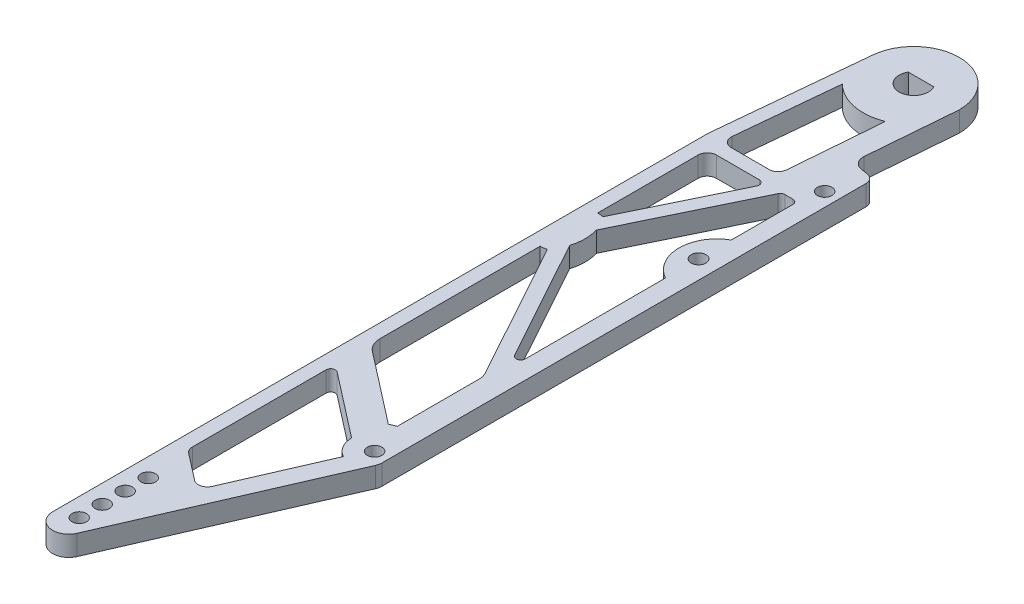
from build123d import *

# Parameters (mm, degrees)
SKETCH2_R           = 2
SKETCH2_R_2         = 1.999999991
BOSS_EXTRUDE1_DEPTH = 5.588
SKETCH7_R           = 2.032
CUT_EXTRUDE1_DEPTH  = 5.588


with BuildPart() as part:
    # Sketch2 → Boss-Extrude1 (new body)
    with BuildSketch(Plane(origin=(0, 0, 0), x_dir=(1, 0, 0), z_dir=(0, 1, 0))):
        with BuildLine():
            ThreePointArc((17.295902343, -30.526810701), (16.688093876, -28.878103365), (15.15555913, -28.018449791))
            Line((15.15555913, -28.018449791), (13.238676936, -27.713033224))
            ThreePointArc((13.238676936, -27.713033224), (11.241051513, -26.538356195), (10.573787778, -24.319092227))
            Line((10.573787778, -24.319092227), (12.5603, 0))
            ThreePointArc((12.5603, 0), (0.603657177, 12.545785512), (-12.502275592, 1.2059192))
            Line((-12.502275592, 1.2059192), (-16.498266045, -40.222207921))
            ThreePointArc((-16.498266045, -40.222207921), (-16.507064815, -40.344000039), (-16.51, -40.466074291))
            Line((-16.51, -40.466074291), (-16.51, -221.328861788))
            ThreePointArc((-16.51, -221.328861788), (-12.970187584, -225.680718913), (-7.988667969, -223.101301399))
            Line((-7.988667969, -223.101301399), (16.979901226, -165.677523619))
            ThreePointArc((16.979901226, -165.677523619), (17.216065593, -164.934164738), (17.295902343, -164.158289667))
            Line((17.295902343, -164.158289667), (17.295902343, -30.526810701))
        make_face()
        with Locations((-11.43, -219.075)):
            Circle(SKETCH2_R, mode=Mode.SUBTRACT)
        with Locations((-11.43, -212.725)):
            Circle(SKETCH2_R, mode=Mode.SUBTRACT)
        with Locations((-11.43, -206.375)):
            Circle(SKETCH2_R, mode=Mode.SUBTRACT)
        with Locations((-11.43, -200.025)):
            Circle(SKETCH2_R, mode=Mode.SUBTRACT)
        with BuildLine():
            ThreePointArc((7.135902343, -162.410770806), (8.023611961, -165.648962244), (10.438542905, -167.981776143))
            Line((10.438542905, -167.981776143), (-0.534170778, -193.217289931))
            ThreePointArc((-0.534170778, -193.217289931), (-2.234040931, -194.665234867), (-4.420389569, -194.211381682))
            Line((-4.420389569, -194.211381682), (-11.716886202, -188.551043102))
            ThreePointArc((-11.716886202, -188.551043102), (-12.441018517, -187.661516081), (-12.7, -186.544128716))
            Line((-12.7, -186.544128716), (-12.7, -149.615408258))
            ThreePointArc((-12.7, -149.615408258), (-11.988693683, -148.474898999), (-10.651556899, -148.611951065))
            Line((-10.651556899, -148.611951065), (7.135902343, -162.410770806))
        make_face(mode=Mode.SUBTRACT)
        with BuildLine():
            ThreePointArc((10.656105825, -153.315833936), (9.771695946, -153.639779081), (8.923603828, -154.049487576))
            Line((8.923603828, -154.049487576), (-10.733772403, -138.80005889))
            ThreePointArc((-10.733772403, -138.80005889), (-12.182037035, -137.021004847), (-12.7, -134.786230117))
            Line((-12.7, -134.786230117), (-12.7, -90.4875))
            ThreePointArc((-12.7, -90.4875), (-11.803536501, -90.43671411), (-10.918544548, -90.285006317))
            Line((-10.918544548, -90.285006317), (10.027134635, -128.362607876))
            ThreePointArc((10.027134635, -128.362607876), (10.49635106, -129.547067395), (10.656105825, -130.811024207))
            Line((10.656105825, -130.811024207), (10.656105825, -153.315833936))
        make_face(mode=Mode.SUBTRACT)
        with Locations((13.485902343, -162.410770806)):
            Circle(SKETCH2_R, mode=Mode.SUBTRACT)
        with BuildLine():
            Line((-10.16, -44.337182032), (1.663048834, -44.337182032))
            ThreePointArc((1.663048834, -44.337182032), (2.739129831, -44.932682449), (2.806066447, -46.160725831))
            Line((2.806066447, -46.160725831), (-11.055993219, -74.784618621))
            ThreePointArc((-11.055993219, -74.784618621), (-11.873503915, -74.655646925), (-12.7, -74.6125))
            Line((-12.7, -74.6125), (-12.7, -46.877182032))
            ThreePointArc((-12.7, -46.877182032), (-11.956051224, -45.081130808), (-10.16, -44.337182032))
        make_face(mode=Mode.SUBTRACT)
        with BuildLine():
            ThreePointArc((-9.903213406, -40.527182032), (-11.783508673, -39.694838236), (-12.431479451, -37.743315662))
            Line((-12.431479451, -37.743315662), (-9.755434212, -9.99962016))
            ThreePointArc((-9.755434212, -9.99962016), (-2.756273581, -13.695395429), (5.127655889, -12.99492382))
            Line((5.127655889, -12.99492382), (3.069264048, -38.19397392))
            ThreePointArc((3.069264048, -38.19397392), (2.259083254, -39.854914801), (0.537695935, -40.527182032))
            Line((0.537695935, -40.527182032), (-9.903213406, -40.527182032))
        make_face(mode=Mode.SUBTRACT)
        with BuildLine():
            Line((-3.521718331, 2), (3.521718331, 2))
            ThreePointArc((3.521718331, 2), (0, -4.05), (-3.521718331, 2))
        make_face(mode=Mode.SUBTRACT)
        with BuildLine():
            ThreePointArc((-8.804706991, -86.222769023), (-8.262040897, -82.55), (-8.804706991, -78.877230977))
            Line((-8.804706991, -78.877230977), (7.575478058, -45.053638233))
            ThreePointArc((7.575478058, -45.053638233), (8.043996088, -44.531101035), (8.718495671, -44.337182032))
            Line((8.718495671, -44.337182032), (10.945902343, -44.337182032))
            ThreePointArc((10.945902343, -44.337182032), (11.843927955, -44.70915642), (12.215902343, -45.607182032))
            Line((12.215902343, -45.607182032), (12.215902343, -62.618124667))
            ThreePointArc((12.215902343, -62.618124667), (6.881902343, -71.709053992), (12.215902343, -80.799983318))
            Line((12.215902343, -80.799983318), (12.215902343, -119.492817968))
            ThreePointArc((12.215902343, -119.492817968), (11.261891546, -120.722879277), (9.83314514, -120.104922051))
            Line((9.83314514, -120.104922051), (-8.804706991, -86.222769023))
        make_face(mode=Mode.SUBTRACT)
        with Locations((13.485902343, -38.1)):
            Circle(SKETCH2_R_2, mode=Mode.SUBTRACT)
    extrude(amount=BOSS_EXTRUDE1_DEPTH)

    # Sketch7 → Cut-Extrude1 (cut)
    with BuildSketch(Plane(origin=(0, 5.588, 0), x_dir=(1, 0, 0), z_dir=(0, 1, 0))):
        with Locations((12.215902343, -71.655983318)):
            Circle(SKETCH7_R)
    extrude(amount=-CUT_EXTRUDE1_DEPTH, mode=Mode.SUBTRACT)


solid = part.part
